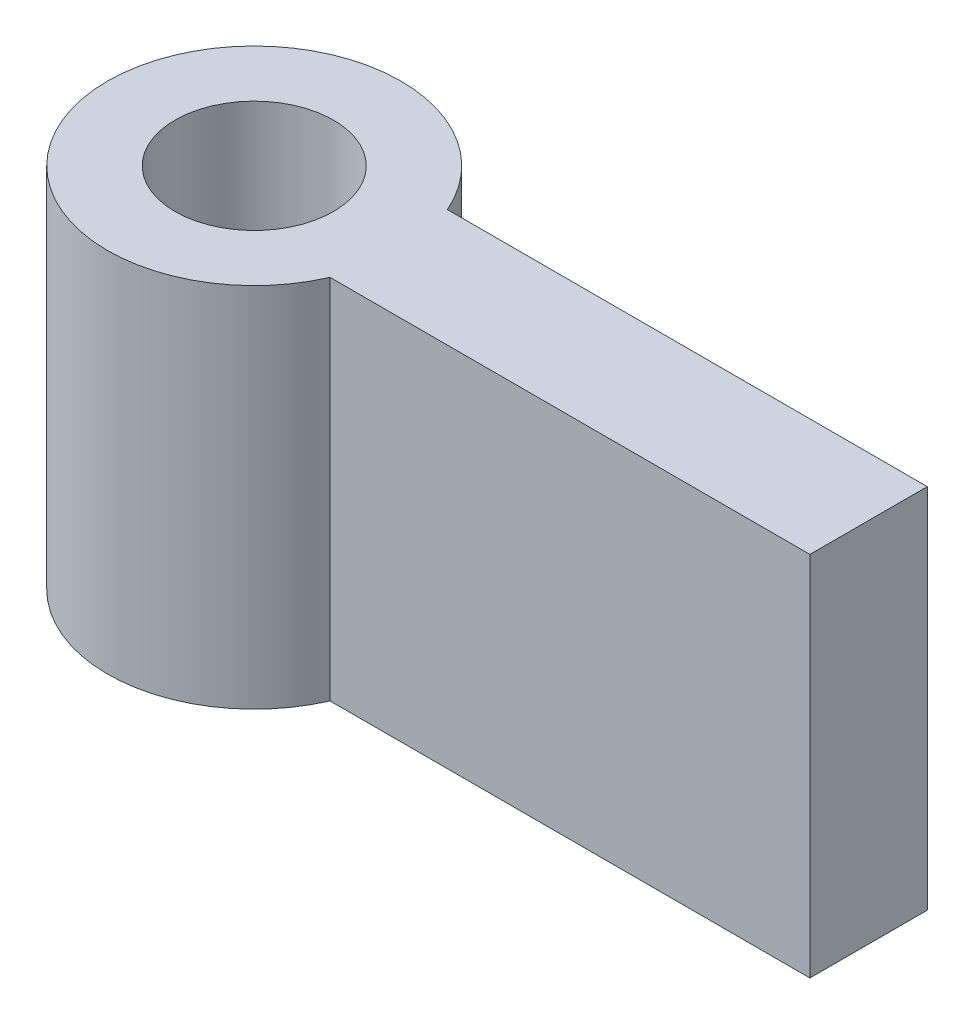
from build123d import *

# Parameters (mm, degrees)
BOSS_EXTRUDE1_DEPTH = 15.875
SKETCH5_R           = 3.429
CUT_EXTRUDE1_DEPTH  = 25.4


with BuildPart() as part:
    # Sketch2 → Boss-Extrude1 (new body)
    with BuildSketch(Plane(origin=(0, 0, 0), x_dir=(1, 0, 0), z_dir=(0, 1, 0))):
        with BuildLine():
            Line((0, 0), (20.765796053, 0))
            Line((20.765796053, 0), (20.765796053, 5.08))
            Line((20.765796053, 5.08), (2.6053e-05, 5.08))
            ThreePointArc((2.6053e-05, 5.08), (-12.169858106, 2.540062415), (0, 0))
        make_face()
    extrude(amount=BOSS_EXTRUDE1_DEPTH)

    # Sketch5 → Cut-Extrude1 (cut)
    with BuildSketch(Plane(origin=(0, 15.875, 0), x_dir=(1, 0, 0), z_dir=(0, 1, 0))):
        with Locations((-5.819858106, 2.540029848)):
            Circle(SKETCH5_R)
    extrude(amount=-CUT_EXTRUDE1_DEPTH, mode=Mode.SUBTRACT)


solid = part.part
